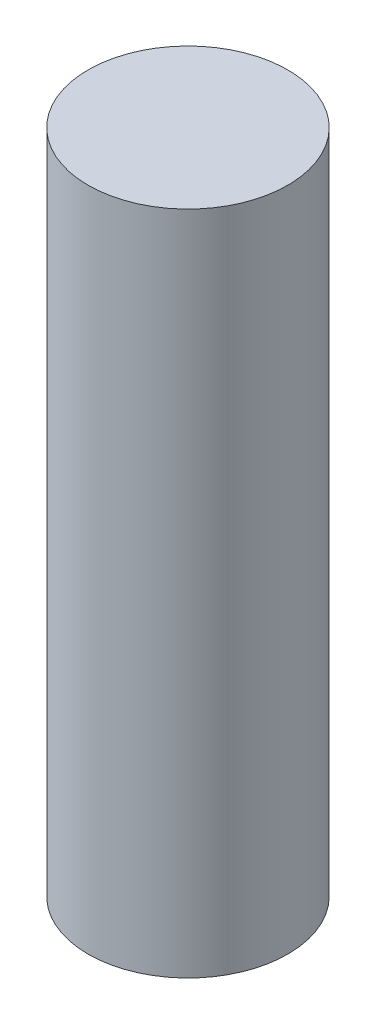
from build123d import *

# Parameters (mm, degrees)
SKETCH1_R           = 0.75
BOSS_EXTRUDE1_DEPTH = 5


with BuildPart() as part:
    # Sketch1 → Boss-Extrude1 (new body)
    with BuildSketch(Plane(origin=(0, 0, 0), x_dir=(1, 0, 0), z_dir=(0, 1, 0))):
        Circle(SKETCH1_R)
    extrude(amount=BOSS_EXTRUDE1_DEPTH)


solid = part.part
